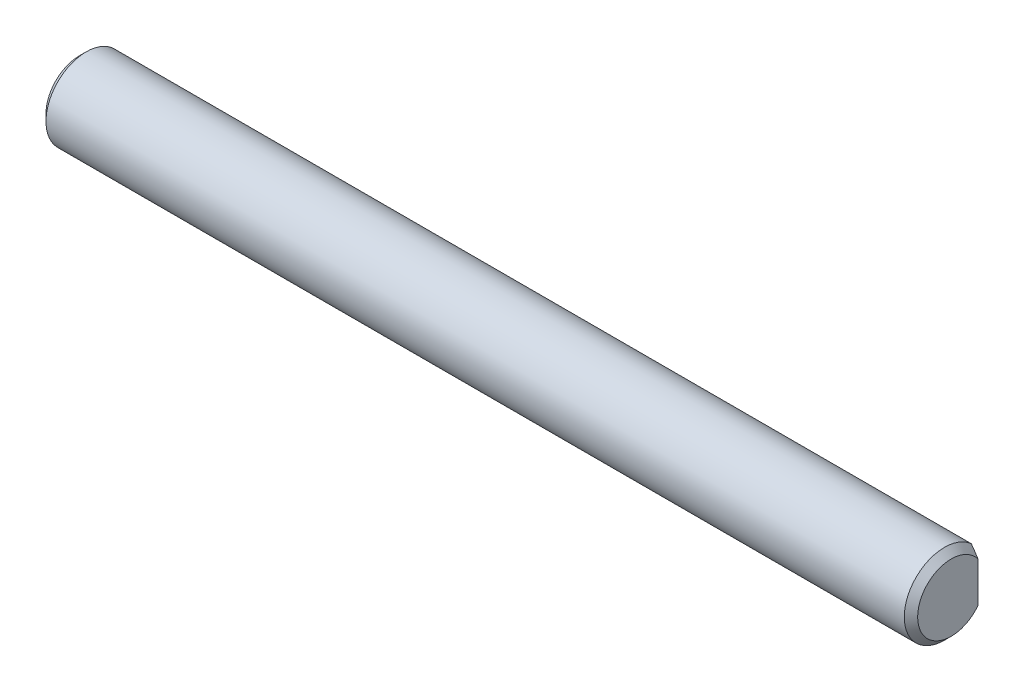
from build123d import *

# Parameters (mm, degrees)
SKETCH1_R           = 3
BOSS_EXTRUDE1_DEPTH = 65
CHAMFER1_SIZE       = 0.5
CUT_EXTRUDE1_DEPTH  = 8


with BuildPart() as part:
    # Sketch1 → Boss-Extrude1 (new body)
    with BuildSketch(Plane(origin=(0, 0, 0), x_dir=(0, 0, -1), z_dir=(1, 0, 0))):
        Circle(SKETCH1_R)
    extrude(amount=BOSS_EXTRUDE1_DEPTH)

    # Chamfer1
    chamfer1_edges = [part.edges().sort_by_distance(p)[0] for p in [
        (0, 0, 3),
        (65, 0, 3),
    ]]
    chamfer(chamfer1_edges, length=CHAMFER1_SIZE)

    # Sketch2 → Cut-Extrude1 (cut)
    with BuildSketch(Plane(origin=(65, 0, 0), x_dir=(0, 0, -1), z_dir=(1, 0, 0))):
        with BuildLine():
            Line((2, 3.200559859), (2, -3.200559859))
            ThreePointArc((2, -3.200559859), (5.959294163, 0), (2, 3.200559859))
        make_face()
    extrude(amount=-CUT_EXTRUDE1_DEPTH, mode=Mode.SUBTRACT)


solid = part.part
